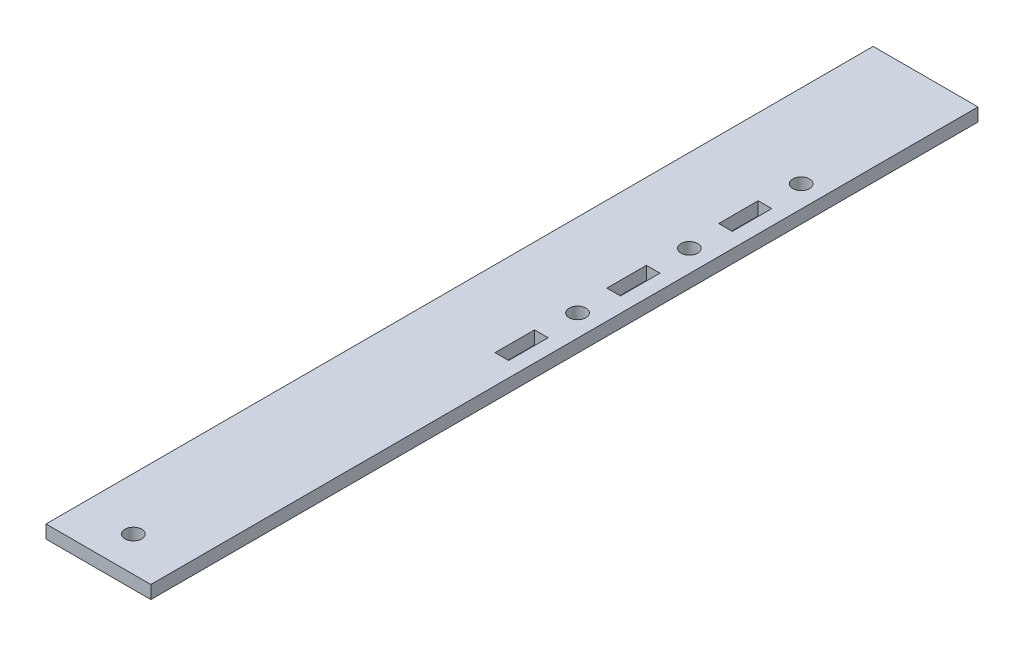
from build123d import *

# Parameters (mm, degrees)
SKETCH1_W           = 19.05
SKETCH1_H           = 2.38125
BOSS_EXTRUDE1_DEPTH = 88.9
SKETCH5_R           = 1.524
CUT_EXTRUDE4_DEPTH  = 3.38125
SKETCH9_W           = 19.05
SKETCH9_H           = 29.6545
BOSS_EXTRUDE4_DEPTH = 2.38125
SKETCH10_W          = 2.47269
SKETCH10_H          = 3.58775
SKETCH10_R          = 1.524
CUT_EXTRUDE5_DEPTH  = 3.38125
BOSS_EXTRUDE5_DEPTH = 2.38125
SKETCH11_R          = 1.524
CUT_EXTRUDE6_DEPTH  = 3.38125


with BuildPart() as part:
    # Sketch1 → Boss-Extrude1 (new body)
    with BuildSketch(Plane.XY):
        with Locations((9.525, 1.190625)):
            Rectangle(SKETCH1_W, SKETCH1_H)
    extrude(amount=BOSS_EXTRUDE1_DEPTH)

    # Sketch5 → Cut-Extrude4 (cut, through all)
    with BuildSketch(Plane(origin=(0, 2.38125, 0), x_dir=(1, 0, 0), z_dir=(0, 1, 0))):
        with Locations((15.08125, -39.14775)):
            Circle(SKETCH5_R)
        with Locations((15.08125, -18.82775)):
            Circle(SKETCH5_R)
        Polygon((16.317595, -28.98775), (16.317595, -32.5755), (15.08125, -32.5755), (13.844905, -32.5755), (13.844905, -25.4), (16.317595, -25.4), align=None)
        Polygon((15.08125, -52.8955), (16.317595, -52.8955), (16.317595, -45.72), (13.844905, -45.72), (13.844905, -52.8955), align=None)
    extrude(amount=-CUT_EXTRUDE4_DEPTH, mode=Mode.SUBTRACT)

    # Sketch9 → Boss-Extrude4 (add)
    with BuildSketch(Plane(origin=(0, 2.38125, 0), x_dir=(1, 0, 0), z_dir=(0, 1, 0))):
        with Locations((9.525, 14.82725)):
            Rectangle(SKETCH9_W, SKETCH9_H)
    extrude(amount=-BOSS_EXTRUDE4_DEPTH)

    # Sketch10 → Cut-Extrude5 (cut, through all)
    with BuildSketch(Plane(origin=(0, 2.38125, 0), x_dir=(1, 0, 0), z_dir=(0, 1, 0))):
        with Locations((15.08125, -6.873875)):
            Rectangle(SKETCH10_W, SKETCH10_H)
        with Locations((15.08125, -10.461625)):
            Rectangle(SKETCH10_W, SKETCH10_H)
        with Locations((15.08125, 1.49225)):
            Circle(SKETCH10_R)
    extrude(amount=-CUT_EXTRUDE5_DEPTH, mode=Mode.SUBTRACT)

    # Sketch8 → Boss-Extrude5 (add)
    with BuildSketch(Plane(origin=(0, 2.38125, 0), x_dir=(1, 0, 0), z_dir=(0, 1, 0))):
        Polygon((19.05, -88.9), (0, -88.9), (0, -114.3), (0, -120.65), (19.05, -120.65), (19.05, -114.3), align=None)
    extrude(amount=-BOSS_EXTRUDE5_DEPTH)

    # Sketch11 → Cut-Extrude6 (cut, through all)
    with BuildSketch(Plane(origin=(0, 2.38125, 0), x_dir=(1, 0, 0), z_dir=(0, 1, 0))):
        with Locations((9.525, -114.3)):
            Circle(SKETCH11_R)
    extrude(amount=-CUT_EXTRUDE6_DEPTH, mode=Mode.SUBTRACT)


solid = part.part
